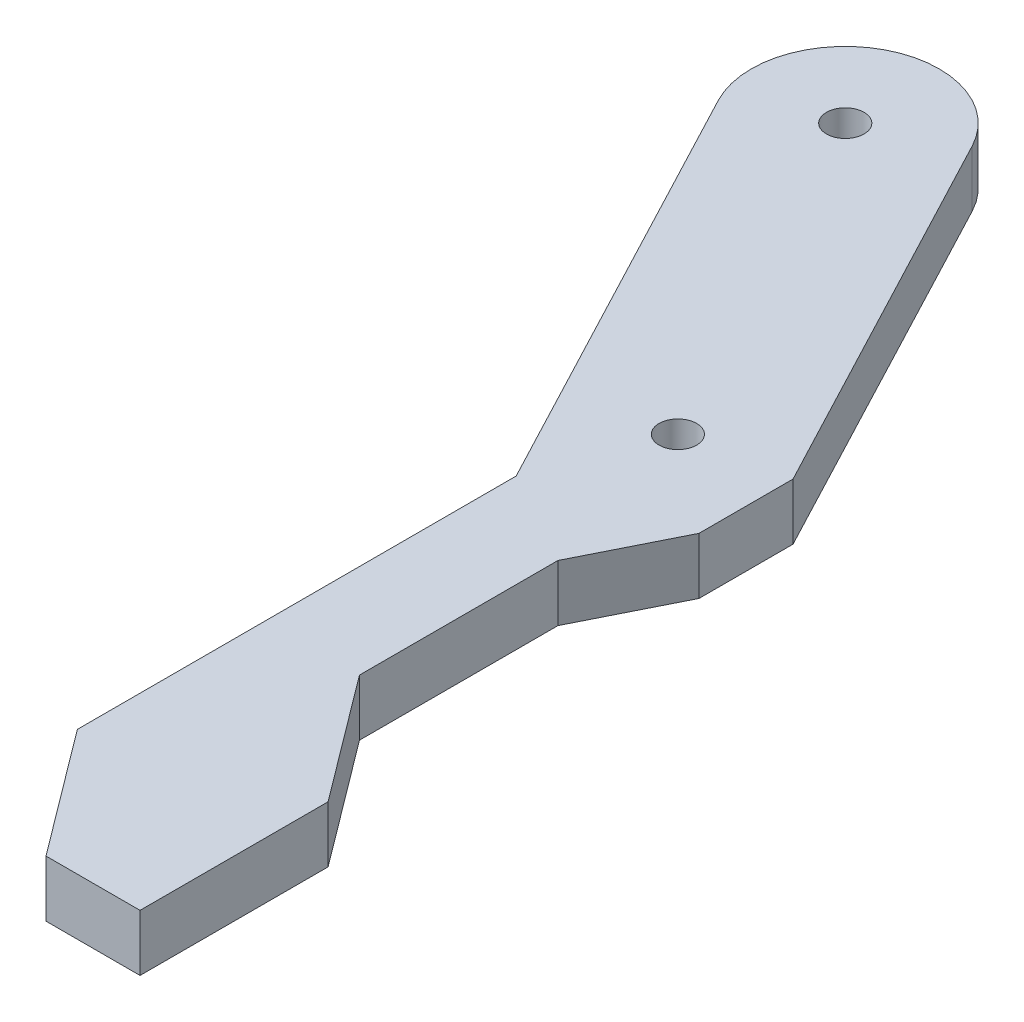
from build123d import *

# Parameters (mm, degrees)
CROQUIS1_R              = 1
SALIENTE_EXTRUIR1_DEPTH = 3


with BuildPart() as part:
    # Croquis1 → Saliente-Extruir1 (new body)
    with BuildSketch(Plane(origin=(0, 0, 0), x_dir=(1, 0, 0), z_dir=(0, 1, 0))):
        with BuildLine():
            Line((-1.930199007, 22.227708448), (9.995007766, -0.44472952))
            Line((9.995007766, -0.44472952), (9.995007766, -23.778062853))
            Line((9.995007766, -23.778062853), (14.995007766, -30.44472952))
            Line((14.995007766, -30.44472952), (19.995007766, -30.44472952))
            Line((19.995007766, -30.44472952), (19.995007766, -20.44472952))
            Line((19.995007766, -20.44472952), (14.995007766, -13.778062853))
            Line((14.995007766, -13.778062853), (14.995007766, -3.222172626))
            Line((14.995007766, -3.222172626), (17.495007766, 1.777827374))
            Line((17.495007766, 1.777827374), (17.495007766, 6.777827374))
            Line((17.495007766, 6.777827374), (6.920214539, 26.882832512))
            ThreePointArc((6.920214539, 26.882832512), (0.167445734, 28.980477254), (-1.930199007, 22.227708448))
        make_face()
        with Locations((2.495007766, 24.55527048)):
            Circle(CROQUIS1_R, mode=Mode.SUBTRACT)
        with Locations((12.371532383, 5.777827374)):
            Circle(CROQUIS1_R, mode=Mode.SUBTRACT)
    extrude(amount=SALIENTE_EXTRUIR1_DEPTH)


solid = part.part
